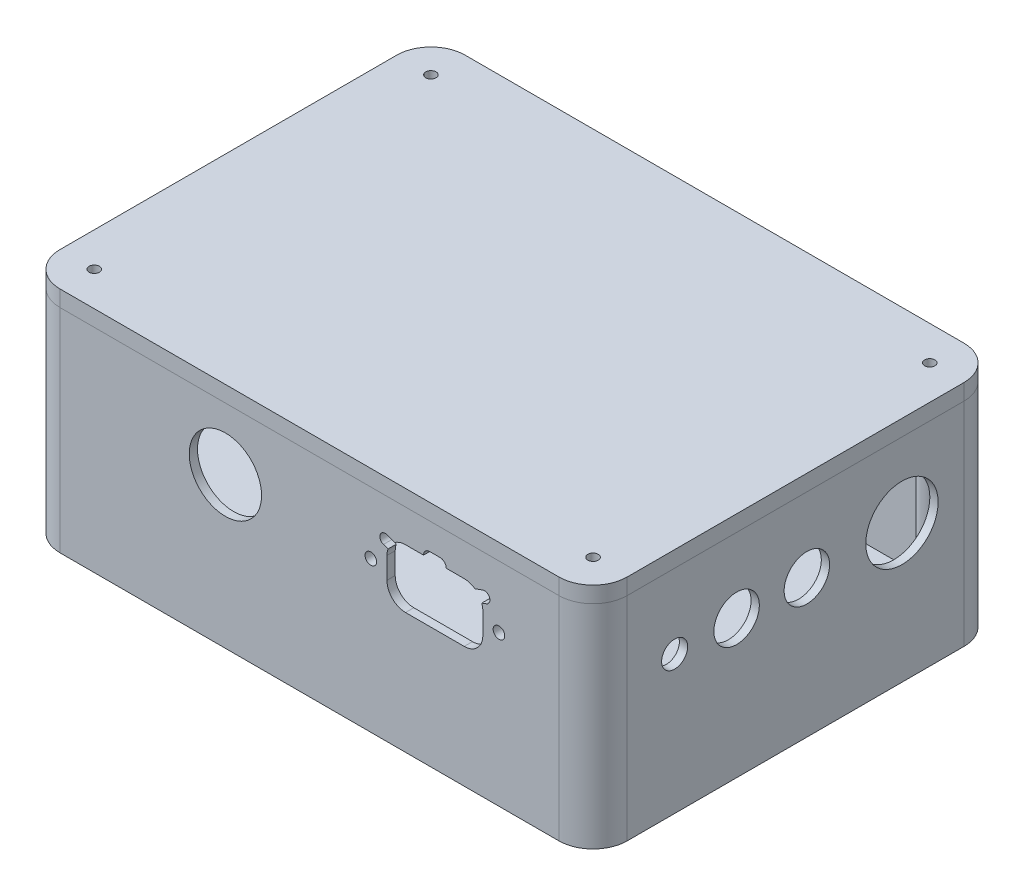
from build123d import *

# Parameters (mm, degrees)
SIDES_DEPTH           = 60.96
SKETCH1_R             = 2.9845
SKETCH1_R_2           = 1.5875
SIDES_2_DEPTH         = 60.96
SIDES_3_DEPTH         = 60.96
SIDES_4_DEPTH         = 60.96
SIDES_5_DEPTH         = 60.96
BOTTOM_DEPTH          = 4.318
SKETCH3_R             = 1.5875
LID_DEPTH             = 4.953
SKETCH4_R             = 11.43
POWER_CUTS_DEPTH      = 2.54
SKETCH5_R             = 11.1125
SKETCH5_R_2           = 1.778
ACCUMULATOR_CUT_DEPTH = 2.54
SKETCH6_R             = 4.0005
SKETCH6_R_2           = 6.985
SKETCH6_R_3           = 11.1125
PANEL_CUTS_DEPTH      = 2.54


with BuildPart() as part:
    # Sketch1 → Sides (new body)
    with BuildSketch(Plane(origin=(0, 0, 0), x_dir=(1, 0, 0), z_dir=(0, 1, 0))):
        with BuildLine():
            Line((-76.6347, 62.23), (76.6347, 62.23))
            ThreePointArc((76.6347, 62.23), (84.059321202, 59.154621202), (87.1347, 51.73))
            Line((87.1347, 51.73), (87.1347, -51.73))
            ThreePointArc((87.1347, -51.73), (84.059321202, -59.154621202), (76.6347, -62.23))
            Line((76.6347, -62.23), (-76.6347, -62.23))
            ThreePointArc((-76.6347, -62.23), (-84.059321202, -59.154621202), (-87.1347, -51.73))
            Line((-87.1347, -51.73), (-87.1347, 51.73))
            ThreePointArc((-87.1347, 51.73), (-84.059321202, 59.154621202), (-76.6347, 62.23))
        make_face()
        with BuildLine():
            ThreePointArc((-76.6347, 59.69), (-82.263269978, 57.358569978), (-84.5947, 51.73))
            Line((-84.5947, 51.73), (-84.5947, -51.73))
            ThreePointArc((-84.5947, -51.73), (-82.263269978, -57.358569978), (-76.6347, -59.69))
            Line((-76.6347, -59.69), (76.6347, -59.69))
            ThreePointArc((76.6347, -59.69), (82.263269978, -57.358569978), (84.5947, -51.73))
            Line((84.5947, -51.73), (84.5947, 51.73))
            ThreePointArc((84.5947, 51.73), (82.263269978, 57.358569978), (76.6347, 59.69))
            Line((76.6347, 59.69), (-76.6347, 59.69))
        make_face(mode=Mode.SUBTRACT)
    extrude(amount=SIDES_DEPTH)

    # Sketch2 → Bottom (add)
    with BuildSketch(Plane(origin=(0, 0, 0), x_dir=(1, 0, 0), z_dir=(0, 1, 0))):
        with BuildLine():
            Line((-76.6347, -62.23), (76.6347, -62.23))
            ThreePointArc((76.6347, -62.23), (84.059321202, -59.154621202), (87.1347, -51.73))
            Line((87.1347, -51.73), (87.1347, 51.73))
            ThreePointArc((87.1347, 51.73), (84.059321202, 59.154621202), (76.6347, 62.23))
            Line((76.6347, 62.23), (-76.6347, 62.23))
            ThreePointArc((-76.6347, 62.23), (-84.059321202, 59.154621202), (-87.1347, 51.73))
            Line((-87.1347, 51.73), (-87.1347, -51.73))
            ThreePointArc((-87.1347, -51.73), (-84.059321202, -59.154621202), (-76.6347, -62.23))
        make_face()
    extrude(amount=-BOTTOM_DEPTH)

    # Sketch4 → Power Cuts (cut)
    with BuildSketch(Plane.ZY.offset(87.1347)):
        with Locations((-29.6955, 38.1)):
            Circle(SKETCH4_R)
        with BuildLine():
            Line((7.153, 50.165), (34.458, 50.165))
            ThreePointArc((34.458, 50.165), (36.254051224, 49.421051224), (36.998, 47.625))
            Line((36.998, 47.625), (36.998, 28.575))
            ThreePointArc((36.998, 28.575), (36.254051224, 26.778948776), (34.458, 26.035))
            Line((34.458, 26.035), (7.153, 26.035))
            ThreePointArc((7.153, 26.035), (5.356948776, 26.778948776), (4.613, 28.575))
            Line((4.613, 28.575), (4.613, 47.625))
            ThreePointArc((4.613, 47.625), (5.356948776, 49.421051224), (7.153, 50.165))
        make_face()
    extrude(amount=-POWER_CUTS_DEPTH, mode=Mode.SUBTRACT)

    # Sketch5 → Accumulator Cut (cut)
    with BuildSketch(Plane.XY.offset(62.23)):
        with Locations((-25.8347, 41.91)):
            Circle(SKETCH5_R)
        with Locations((18.8497, 41.91)):
            Circle(SKETCH5_R_2)
        with Locations((58.2197, 41.91)):
            Circle(SKETCH5_R_2)
        with BuildLine():
            Line((23.8027, 45.212), (23.8027, 38.608))
            ThreePointArc((23.8027, 38.608), (25.476584746, 34.566884746), (29.5177, 32.893))
            Line((29.5177, 32.893), (47.5517, 32.893))
            ThreePointArc((47.5517, 32.893), (51.592815254, 34.566884746), (53.2667, 38.608))
            Line((53.2667, 38.608), (53.2667, 45.212))
            ThreePointArc((53.2667, 45.212), (53.184395768, 46.178417808), (52.939853673, 47.117))
            Line((52.939853673, 47.117), (54.344214304, 47.613516463))
            ThreePointArc((54.344214304, 47.613516463), (55.350458699, 49.720427524), (53.243547638, 50.726671918))
            Line((53.243547638, 50.726671918), (50.848812672, 49.880005252))
            ThreePointArc((50.848812672, 49.880005252), (49.281378437, 50.658965899), (47.5517, 50.927))
            Line((47.5517, 50.927), (42.0272, 50.927))
            ThreePointArc((42.0272, 50.927), (41.469238418, 52.274038418), (40.1222, 52.832))
            Line((40.1222, 52.832), (36.9472, 52.832))
            ThreePointArc((36.9472, 52.832), (35.600161582, 52.274038418), (35.0422, 50.927))
            Line((35.0422, 50.927), (29.5177, 50.927))
            ThreePointArc((29.5177, 50.927), (27.788021563, 50.658965899), (26.220587328, 49.880005252))
            Line((26.220587328, 49.880005252), (23.825852362, 50.726671918))
            ThreePointArc((23.825852362, 50.726671918), (21.718941301, 49.720427524), (22.725185696, 47.613516463))
            Line((22.725185696, 47.613516463), (24.129546327, 47.117))
            ThreePointArc((24.129546327, 47.117), (23.885004232, 46.178417808), (23.8027, 45.212))
        make_face()
    extrude(amount=-ACCUMULATOR_CUT_DEPTH, mode=Mode.SUBTRACT)

    # Sketch6 → Panel Cuts (cut)
    with BuildSketch(Plane(origin=(87.1347, 0, 0), x_dir=(0, 0, -1), z_dir=(1, 0, 0))):
        with Locations((-37.17, 38.1)):
            Circle(SKETCH6_R)
        with Locations((-18.12, 38.1)):
            Circle(SKETCH6_R_2)
        with Locations((3.47, 38.1)):
            Circle(SKETCH6_R_2)
        with Locations((32.68, 38.1)):
            Circle(SKETCH6_R_3)
    extrude(amount=-PANEL_CUTS_DEPTH, mode=Mode.SUBTRACT)


with BuildPart() as body_2:
    # Sketch1 → Sides 2 (new body)
    with BuildSketch(Plane(origin=(0, 0, 0), x_dir=(1, 0, 0), z_dir=(0, 1, 0))):
        with Locations((-76.6347, 51.73)):
            Circle(SKETCH1_R)
        with Locations((-76.6347, 51.73)):
            Circle(SKETCH1_R_2, mode=Mode.SUBTRACT)
    extrude(amount=SIDES_2_DEPTH)


with BuildPart() as body_3:
    # Sketch1 → Sides 3 (new body)
    with BuildSketch(Plane(origin=(0, 0, 0), x_dir=(1, 0, 0), z_dir=(0, 1, 0))):
        with Locations((76.6347, 51.73)):
            Circle(SKETCH1_R)
        with Locations((76.6347, 51.73)):
            Circle(SKETCH1_R_2, mode=Mode.SUBTRACT)
    extrude(amount=SIDES_3_DEPTH)


with BuildPart() as body_4:
    # Sketch1 → Sides 4 (new body)
    with BuildSketch(Plane(origin=(0, 0, 0), x_dir=(1, 0, 0), z_dir=(0, 1, 0))):
        with Locations((76.6347, -51.73)):
            Circle(SKETCH1_R)
        with Locations((76.6347, -51.73)):
            Circle(SKETCH1_R_2, mode=Mode.SUBTRACT)
    extrude(amount=SIDES_4_DEPTH)


with BuildPart() as body_5:
    # Sketch1 → Sides 5 (new body)
    with BuildSketch(Plane(origin=(0, 0, 0), x_dir=(1, 0, 0), z_dir=(0, 1, 0))):
        with Locations((-76.6347, -51.73)):
            Circle(SKETCH1_R)
        with Locations((-76.6347, -51.73)):
            Circle(SKETCH1_R_2, mode=Mode.SUBTRACT)
    extrude(amount=SIDES_5_DEPTH)


with BuildPart() as body_6:
    # Sketch3 → Lid (new body)
    with BuildSketch(Plane(origin=(0, 60.96, 0), x_dir=(1, 0, 0), z_dir=(0, 1, 0))):
        with BuildLine():
            Line((-87.1347, 51.73), (-87.1347, -51.73))
            ThreePointArc((-87.1347, -51.73), (-84.059321202, -59.154621202), (-76.6347, -62.23))
            Line((-76.6347, -62.23), (76.6347, -62.23))
            ThreePointArc((76.6347, -62.23), (84.059321202, -59.154621202), (87.1347, -51.73))
            Line((87.1347, -51.73), (87.1347, 51.73))
            ThreePointArc((87.1347, 51.73), (84.059321202, 59.154621202), (76.6347, 62.23))
            Line((76.6347, 62.23), (-76.6347, 62.23))
            ThreePointArc((-76.6347, 62.23), (-84.059321202, 59.154621202), (-87.1347, 51.73))
        make_face()
        with Locations((76.6347, 51.73)):
            Circle(SKETCH3_R, mode=Mode.SUBTRACT)
        with Locations((76.6347, -51.73)):
            Circle(SKETCH3_R, mode=Mode.SUBTRACT)
        with Locations((-76.6347, -51.73)):
            Circle(SKETCH3_R, mode=Mode.SUBTRACT)
        with Locations((-76.6347, 51.73)):
            Circle(SKETCH3_R, mode=Mode.SUBTRACT)
    extrude(amount=LID_DEPTH)


solid = Compound([part.part, body_2.part, body_3.part, body_4.part, body_5.part, body_6.part])
